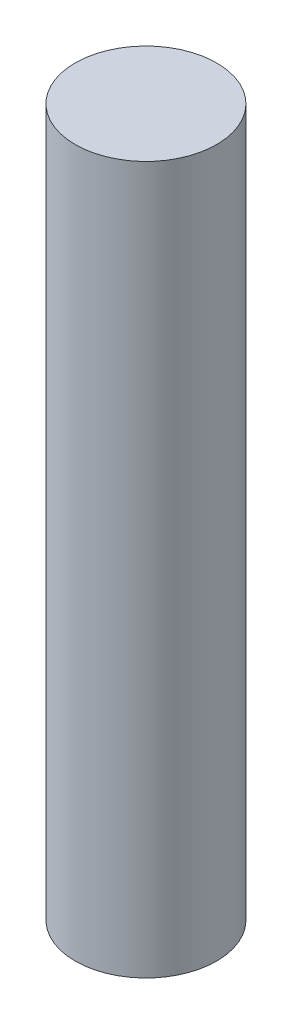
from build123d import *

# Parameters (mm, degrees)
SKETCH1_R           = 3.175
BOSS_EXTRUDE1_DEPTH = 31.75


with BuildPart() as part:
    # Sketch1 → Boss-Extrude1 (new body)
    with BuildSketch(Plane(origin=(0, 0, 0), x_dir=(1, 0, 0), z_dir=(0, 1, 0))):
        Circle(SKETCH1_R)
    extrude(amount=BOSS_EXTRUDE1_DEPTH)


solid = part.part
